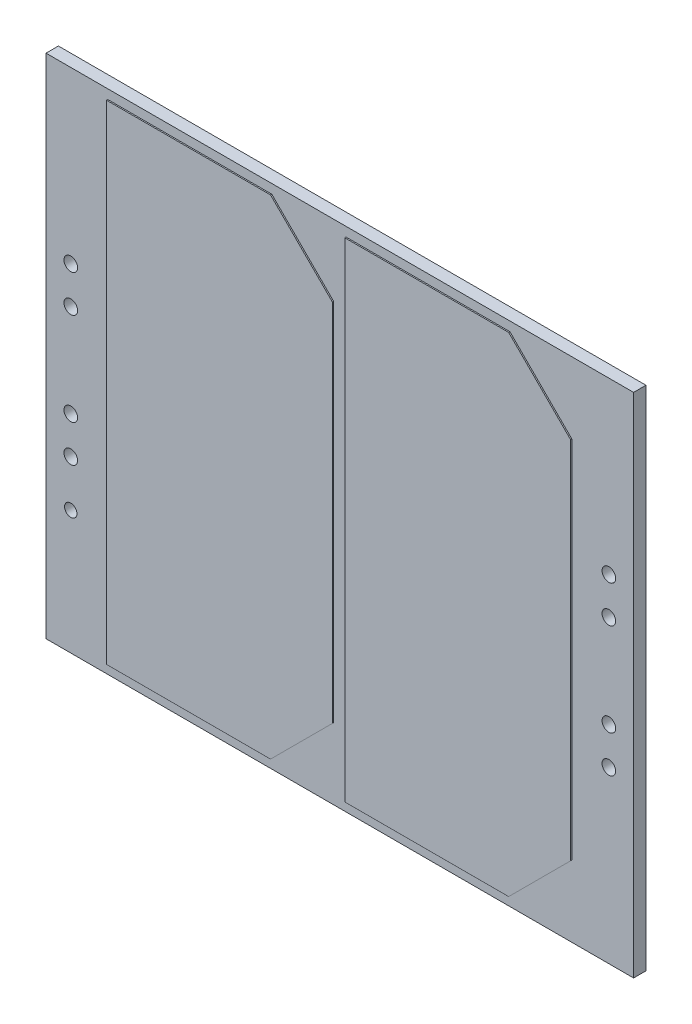
from build123d import *

# Parameters (mm, degrees)
SKETCH1_W           = 95
SKETCH1_H           = 82
SKETCH1_R           = 1.1
SKETCH1_R_2         = 1
BOSS_EXTRUDE1_DEPTH = 2
BOSS_EXTRUDE2_DEPTH = 0.2


with BuildPart() as part:
    # Sketch1 → Boss-Extrude1 (new body)
    with BuildSketch(Plane.XY):
        Rectangle(SKETCH1_W, SKETCH1_H)
        with Locations((-43.5, 13.5)):
            Circle(SKETCH1_R, mode=Mode.SUBTRACT)
        with Locations((-43.5, -13.5)):
            Circle(SKETCH1_R, mode=Mode.SUBTRACT)
        with Locations((43.5, 7.5)):
            Circle(SKETCH1_R, mode=Mode.SUBTRACT)
        with Locations((43.5, -7.5)):
            Circle(SKETCH1_R, mode=Mode.SUBTRACT)
        with Locations((-43.5, 7.5)):
            Circle(SKETCH1_R, mode=Mode.SUBTRACT)
        with Locations((-43.5, -7.5)):
            Circle(SKETCH1_R, mode=Mode.SUBTRACT)
        with Locations((43.5, 13.5)):
            Circle(SKETCH1_R, mode=Mode.SUBTRACT)
        with Locations((43.5, -13.5)):
            Circle(SKETCH1_R, mode=Mode.SUBTRACT)
        with Locations((-43.5, -21)):
            Circle(SKETCH1_R_2, mode=Mode.SUBTRACT)
    extrude(amount=BOSS_EXTRUDE1_DEPTH)

    # Sketch2 → Boss-Extrude2 (add)
    with BuildSketch(Plane.XY.offset(2)):
        Polygon((-11, 39.5), (-1, 29.5), (-1, -29.5), (-11, -39.5), (-37.5, -39.5), (-37.5, 39.5), align=None)
        Polygon((1, 39.5), (27.5, 39.5), (37.5, 29.5), (37.5, -29.5), (27.5, -39.5), (1, -39.5), align=None)
    extrude(amount=BOSS_EXTRUDE2_DEPTH)


solid = part.part
